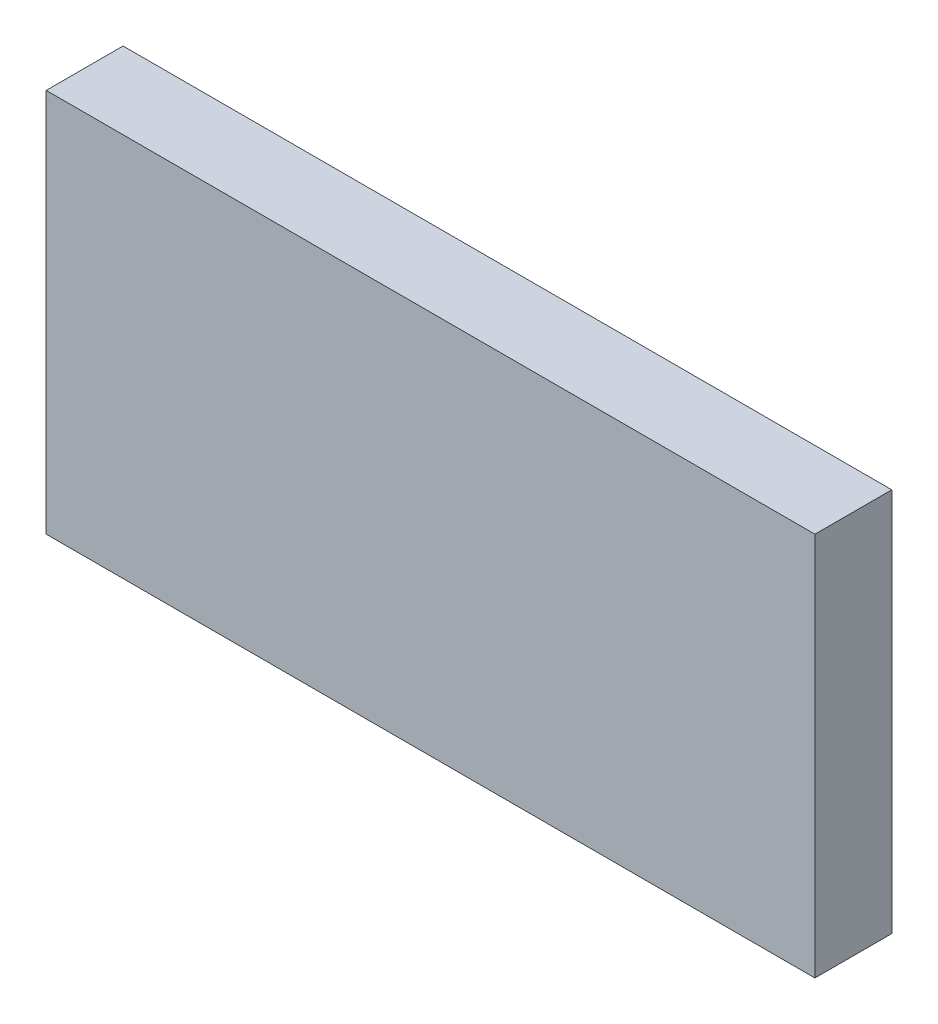
from build123d import *

# Parameters (mm, degrees)
SKETCH_1_W      = 20
SKETCH_1_H      = 10
EXTRUDE_1_DEPTH = 2


with BuildPart() as part:
    # 草图1 → 凸台-拉伸1 (new body)
    with BuildSketch(Plane.XY):
        with Locations((-29.215998547, 19.001764997)):
            Rectangle(SKETCH_1_W, SKETCH_1_H)
    extrude(amount=EXTRUDE_1_DEPTH)


solid = part.part
